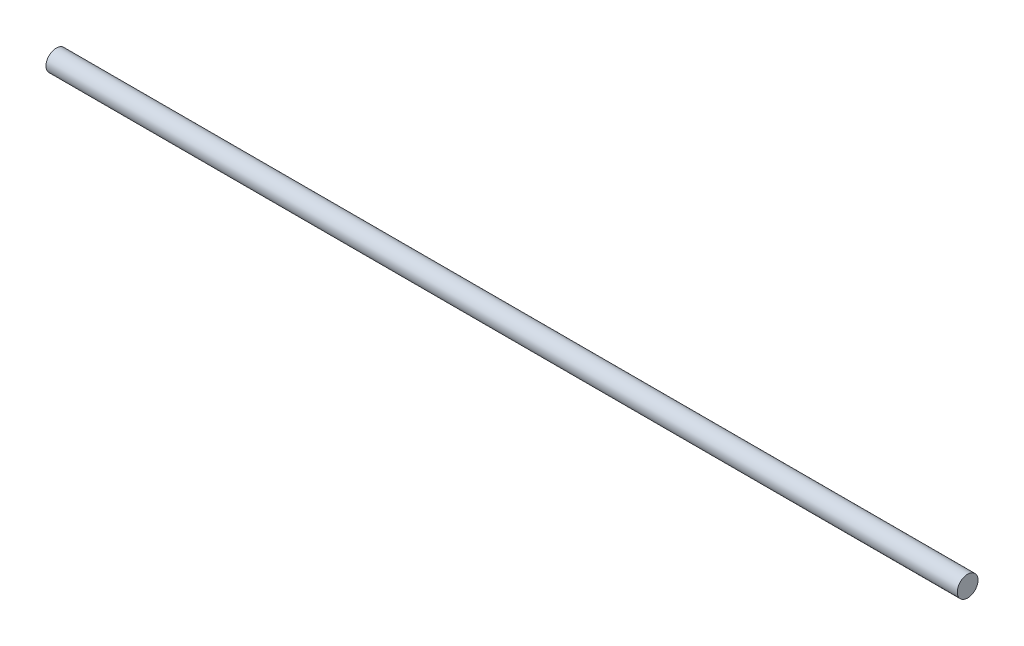
from build123d import *

# Parameters (mm, degrees)
SCHIZZO1_R                   = 2.5
ESTRUSIONE_ESTRUSIONE1_DEPTH = 220


with BuildPart() as part:
    # Schizzo1 → Estrusione-Estrusione1 (new body)
    with BuildSketch(Plane(origin=(0, 0, 0), x_dir=(0, 0, -1), z_dir=(1, 0, 0))):
        Circle(SCHIZZO1_R)
    extrude(amount=ESTRUSIONE_ESTRUSIONE1_DEPTH)


solid = part.part
